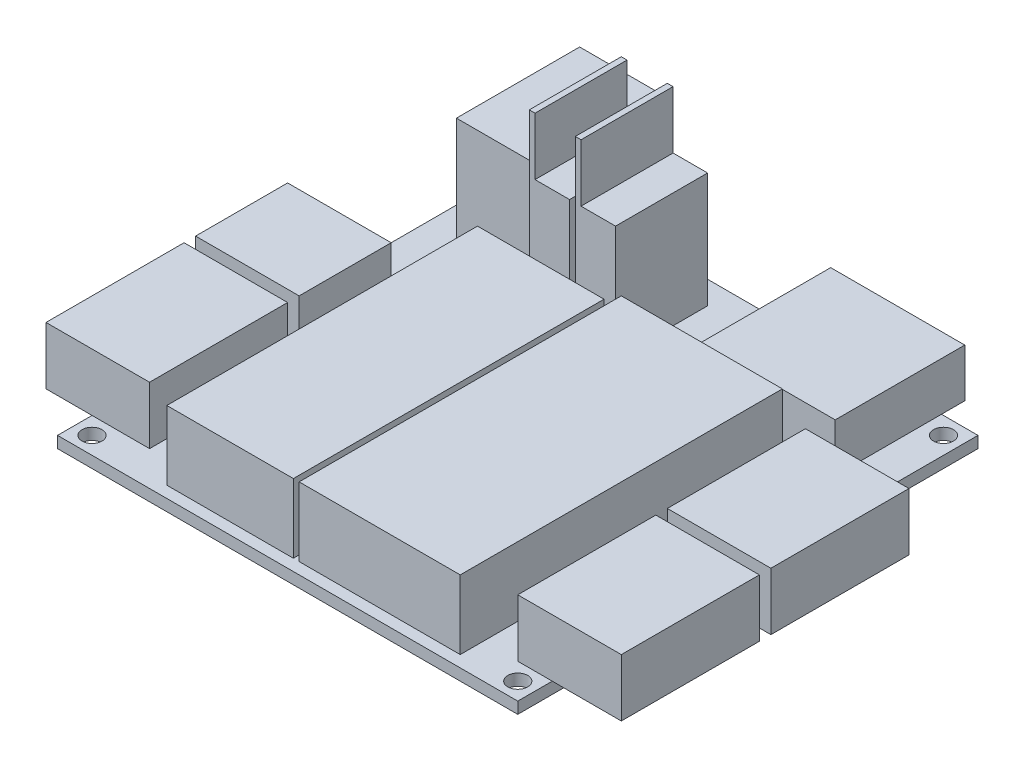
from build123d import *

# Parameters (mm, degrees)
SKETCH3_W           = 50.8
SKETCH3_H           = 50.8
BOSS_EXTRUDE1_DEPTH = 1.27
CUT_EXTRUDE1_REACH  = 3.27
SKETCH4_R           = 1.0999978
SKETCH5_W           = 17.78
SKETCH5_H           = 35.56
SKETCH5_W_2         = 13.97
SKETCH5_H_2         = 34.29
BOSS_EXTRUDE2_DEPTH = 7.62
SKETCH6_W           = 14.8000212
SKETCH6_H           = 14.2999968
BOSS_EXTRUDE3_DEPTH = 5.334
BOSS_EXTRUDE4_DEPTH = 12.7
SKETCH8_W           = 11.43
SKETCH8_H           = 15.24
SKETCH8_H_2         = 10.16
BOSS_EXTRUDE5_DEPTH = 6.35
SKETCH9_W           = 3.81
SKETCH9_H           = 10.16
BOSS_EXTRUDE6_DEPTH = 12.7
SKETCH10_W          = 0.635
SKETCH10_H          = 10.16
BOSS_EXTRUDE7_DEPTH = 19.05


with BuildPart() as part:
    # Sketch3 → Boss-Extrude1 (new body)
    with BuildSketch(Plane(origin=(0, 0, 0), x_dir=(1, 0, 0), z_dir=(0, 1, 0))):
        with Locations((25.4, 25.4)):
            Rectangle(SKETCH3_W, SKETCH3_H)
    extrude(amount=BOSS_EXTRUDE1_DEPTH)

    # Sketch4 → Cut-Extrude1 (cut, up to next)
    with BuildSketch(Plane(origin=(0, 0, 0), x_dir=(1, 0, 0), z_dir=(0, 1, 0)), mode=Mode.PRIVATE) as cut_extrude1_sk1:
        with Locations((1.905, 48.895)):
            Circle(SKETCH4_R)
    cut_extrude1_tool1 = extrude(cut_extrude1_sk1.sketch, amount=CUT_EXTRUDE1_REACH, mode=Mode.PRIVATE) & part.part
    add(cut_extrude1_tool1.solids().sort_by_distance((1.905, 0, -48.895))[0], mode=Mode.SUBTRACT)
    # Sketch4 → Cut-Extrude1 (cut, up to next)
    with BuildSketch(Plane(origin=(0, 0, 0), x_dir=(1, 0, 0), z_dir=(0, 1, 0)), mode=Mode.PRIVATE) as cut_extrude1_sk2:
        with Locations((48.895, 48.895)):
            Circle(SKETCH4_R)
    cut_extrude1_tool2 = extrude(cut_extrude1_sk2.sketch, amount=CUT_EXTRUDE1_REACH, mode=Mode.PRIVATE) & part.part
    add(cut_extrude1_tool2.solids().sort_by_distance((48.895, 0, -48.895))[0], mode=Mode.SUBTRACT)
    # Sketch4 → Cut-Extrude1 (cut, up to next)
    with BuildSketch(Plane(origin=(0, 0, 0), x_dir=(1, 0, 0), z_dir=(0, 1, 0)), mode=Mode.PRIVATE) as cut_extrude1_sk3:
        with Locations((48.895, 1.905)):
            Circle(SKETCH4_R)
    cut_extrude1_tool3 = extrude(cut_extrude1_sk3.sketch, amount=CUT_EXTRUDE1_REACH, mode=Mode.PRIVATE) & part.part
    add(cut_extrude1_tool3.solids().sort_by_distance((48.895, 0, -1.905))[0], mode=Mode.SUBTRACT)
    # Sketch4 → Cut-Extrude1 (cut, up to next)
    with BuildSketch(Plane(origin=(0, 0, 0), x_dir=(1, 0, 0), z_dir=(0, 1, 0)), mode=Mode.PRIVATE) as cut_extrude1_sk4:
        with Locations((1.905, 1.905)):
            Circle(SKETCH4_R)
    cut_extrude1_tool4 = extrude(cut_extrude1_sk4.sketch, amount=CUT_EXTRUDE1_REACH, mode=Mode.PRIVATE) & part.part
    add(cut_extrude1_tool4.solids().sort_by_distance((1.905, 0, -1.905))[0], mode=Mode.SUBTRACT)

    # Sketch5 → Boss-Extrude2 (add)
    with BuildSketch(Plane(origin=(0, 1.27, 0), x_dir=(1, 0, 0), z_dir=(0, 1, 0))):
        with Locations((34.29, 19.05)):
            Rectangle(SKETCH5_W, SKETCH5_H)
        with Locations((17.78, 18.415)):
            Rectangle(SKETCH5_W_2, SKETCH5_H_2)
    extrude(amount=BOSS_EXTRUDE2_DEPTH)

    # Sketch6 → Boss-Extrude3 (add)
    with BuildSketch(Plane(origin=(0, 1.27, 0), x_dir=(1, 0, 0), z_dir=(0, 1, 0))):
        with Locations((39.37, 46.219999)):
            Rectangle(SKETCH6_W, SKETCH6_H)
    extrude(amount=BOSS_EXTRUDE3_DEPTH)

    # Sketch7 → Boss-Extrude4 (add)
    with BuildSketch(Plane(origin=(0, 1.27, 0), x_dir=(1, 0, 0), z_dir=(0, 1, 0))):
        Polygon((4.390009, 53.2400002), (13.389991, 53.2400002), (13.389991, 50.340006), (13.389991, 39.640002), (4.390009, 39.640002), align=None)
    extrude(amount=BOSS_EXTRUDE4_DEPTH)

    # Sketch8 → Boss-Extrude5 (add)
    with BuildSketch(Plane(origin=(0, 1.27, 0), x_dir=(1, 0, 0), z_dir=(0, 1, 0))):
        with Locations((0.635, 11.43)):
            Rectangle(SKETCH8_W, SKETCH8_H)
        with Locations((0.635, 25.4)):
            Rectangle(SKETCH8_W, SKETCH8_H_2)
        with Locations((52.705, 27.94)):
            Rectangle(SKETCH8_W, SKETCH8_H)
        with Locations((52.705, 11.43)):
            Rectangle(SKETCH8_W, SKETCH8_H)
    extrude(amount=BOSS_EXTRUDE5_DEPTH)

    # Sketch9 → Boss-Extrude6 (add)
    with BuildSketch(Plane(origin=(0, 1.27, 0), x_dir=(1, 0, 0), z_dir=(0, 1, 0))):
        with Locations((21.59, 43.18)):
            Rectangle(SKETCH9_W, SKETCH9_H)
        with Locations((16.51, 43.18)):
            Rectangle(SKETCH9_W, SKETCH9_H)
    extrude(amount=BOSS_EXTRUDE6_DEPTH)

    # Sketch10 → Boss-Extrude7 (add)
    with BuildSketch(Plane(origin=(0, 1.27, 0), x_dir=(1, 0, 0), z_dir=(0, 1, 0))):
        with Locations((19.3675, 43.18)):
            Rectangle(SKETCH10_W, SKETCH10_H)
        with Locations((14.2875, 43.18)):
            Rectangle(SKETCH10_W, SKETCH10_H)
    extrude(amount=BOSS_EXTRUDE7_DEPTH)


solid = part.part
